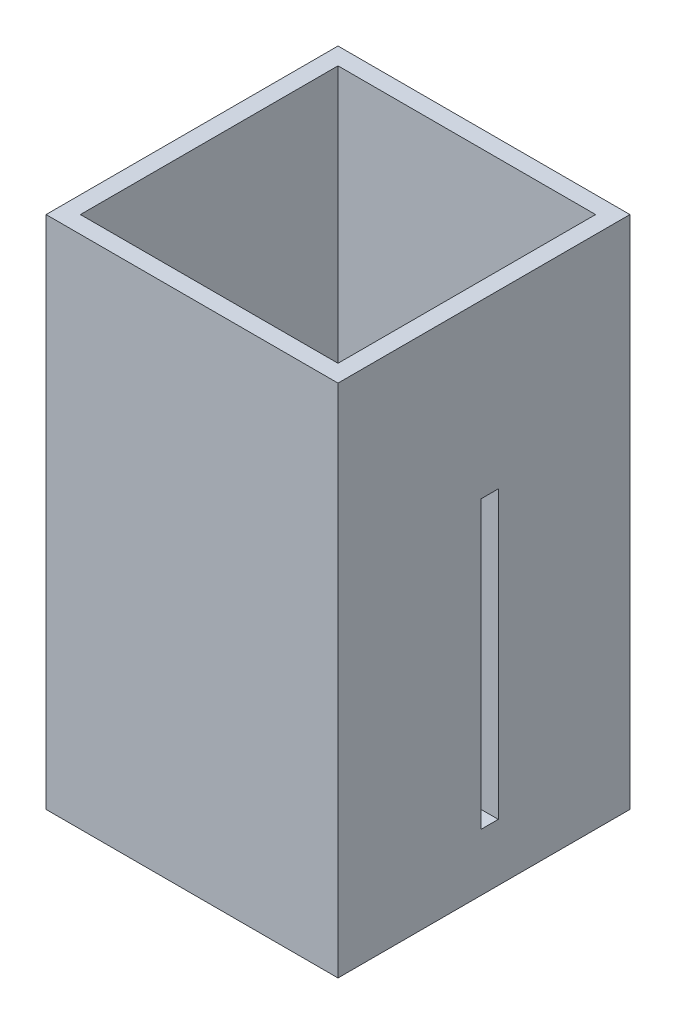
from build123d import *

# Parameters (mm, degrees)
SKETCH1_W               = 51
SKETCH1_H               = 51
BOSS_EXTRUDE1_DEPTH     = 90
SHELL1_T                = -3
SKETCH2_W               = 3
SKETCH2_H               = 50
CUT_EXTRUDE1_DEPTH      = 26.5
CUT_EXTRUDE1_DEPTH_BACK = 26.5
SKETCH5_R               = 15
BOSS_EXTRUDE3_DEPTH     = 10


with BuildPart() as part:
    # Sketch1 → Boss-Extrude1 (new body)
    with BuildSketch(Plane(origin=(0, 0, 0), x_dir=(1, 0, 0), z_dir=(0, 1, 0))):
        Rectangle(SKETCH1_W, SKETCH1_H)
    extrude(amount=BOSS_EXTRUDE1_DEPTH)

    # Shell1
    shell1_openings = [part.faces().sort_by_distance(p)[0] for p in [
        (0, 90, 0),
    ]]
    offset(amount=SHELL1_T, openings=shell1_openings, kind=Kind.INTERSECTION)

    # Sketch2 → Cut-Extrude1 (cut, two sides)
    with BuildSketch(Plane(origin=(0, 0, 0), x_dir=(0, 0, -1), z_dir=(1, 0, 0))) as cut_extrude1_sk:
        with Locations((1, 35)):
            Rectangle(SKETCH2_W, SKETCH2_H)
    extrude(amount=CUT_EXTRUDE1_DEPTH, mode=Mode.SUBTRACT)
    extrude(cut_extrude1_sk.sketch, amount=-CUT_EXTRUDE1_DEPTH_BACK, mode=Mode.SUBTRACT)


with BuildPart() as body_2:
    # Sketch5 → Boss-Extrude3 (new body)
    with BuildSketch(Plane(origin=(0, 10, 0), x_dir=(-1, 0, 0), z_dir=(0, -1, 0))):
        with Locations((0, -2.5)):
            Circle(SKETCH5_R)
    extrude(amount=-BOSS_EXTRUDE3_DEPTH)


solid = Compound([part.part, body_2.part])
